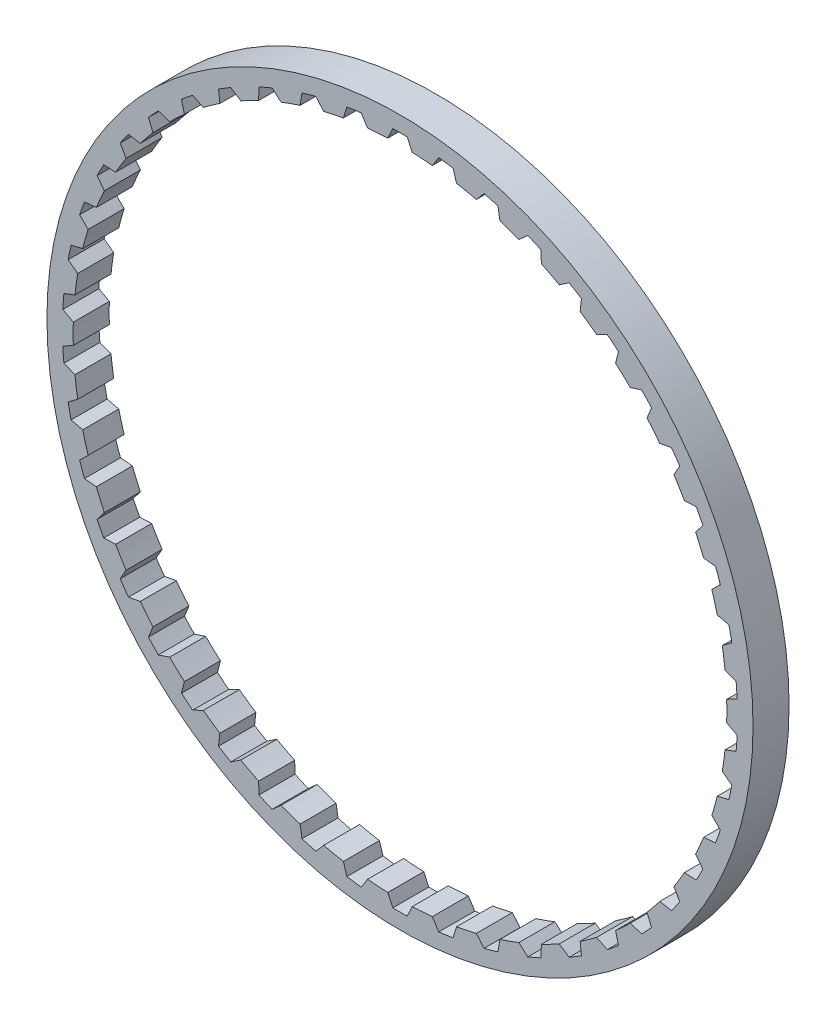
from build123d import *

# Parameters (mm, degrees)
ESQUISSE2_W                  = 10
ESQUISSE2_H                  = 10
ENL_V_MAT_EXTRU_1_DEPTH      = 139.683091976
R_P_TITION_CIRCULAIRE1_COUNT = 46


with BuildPart() as part:
    # Esquisse2 → Révolution1 (revolve)
    with BuildSketch(Plane(origin=(0, 0, 0), x_dir=(0, 0, -1), z_dir=(1, 0, 0))):
        with Locations((0, 93)):
            Rectangle(ESQUISSE2_W, ESQUISSE2_H)
    revolve(axis=Axis((0, 0, 7.636363636), (0, 0, -1)))

    # Esquisse5 → Enlèv. mat.-Extru.1 (cut, symmetric)
    with BuildSketch(Plane.XY):
        with BuildLine():
            Line((-6.25, 90.504452377), (0, 0))
            Line((0, 0), (6.25, 90.504452377))
            ThreePointArc((6.25, 90.504452377), (4.82505891, 90.591595673), (3.398922974, 90.656305476))
            Line((3.398922974, 90.656305476), (2, 93.656305476))
            ThreePointArc((2, 93.656305476), (0, 93.677657718), (-2, 93.656305476))
            Line((-2, 93.656305476), (-3.398922974, 90.656305476))
            ThreePointArc((-3.398922974, 90.656305476), (-4.82505891, 90.591595673), (-6.25, 90.504452377))
        make_face()
    enl_v_mat_extru_1 = extrude(amount=ENL_V_MAT_EXTRU_1_DEPTH, both=True, mode=Mode.SUBTRACT)

    # Répétition circulaire1: Enlèv. mat.-Extru.1 ×46 about axis
    r_p_tition_circulaire1_axis = Axis((0, 0, -5), (0, 0, 1))
    for i in range(1, R_P_TITION_CIRCULAIRE1_COUNT):
        add(enl_v_mat_extru_1.rotate(r_p_tition_circulaire1_axis, i * 360 / R_P_TITION_CIRCULAIRE1_COUNT), mode=Mode.SUBTRACT)


solid = part.part
